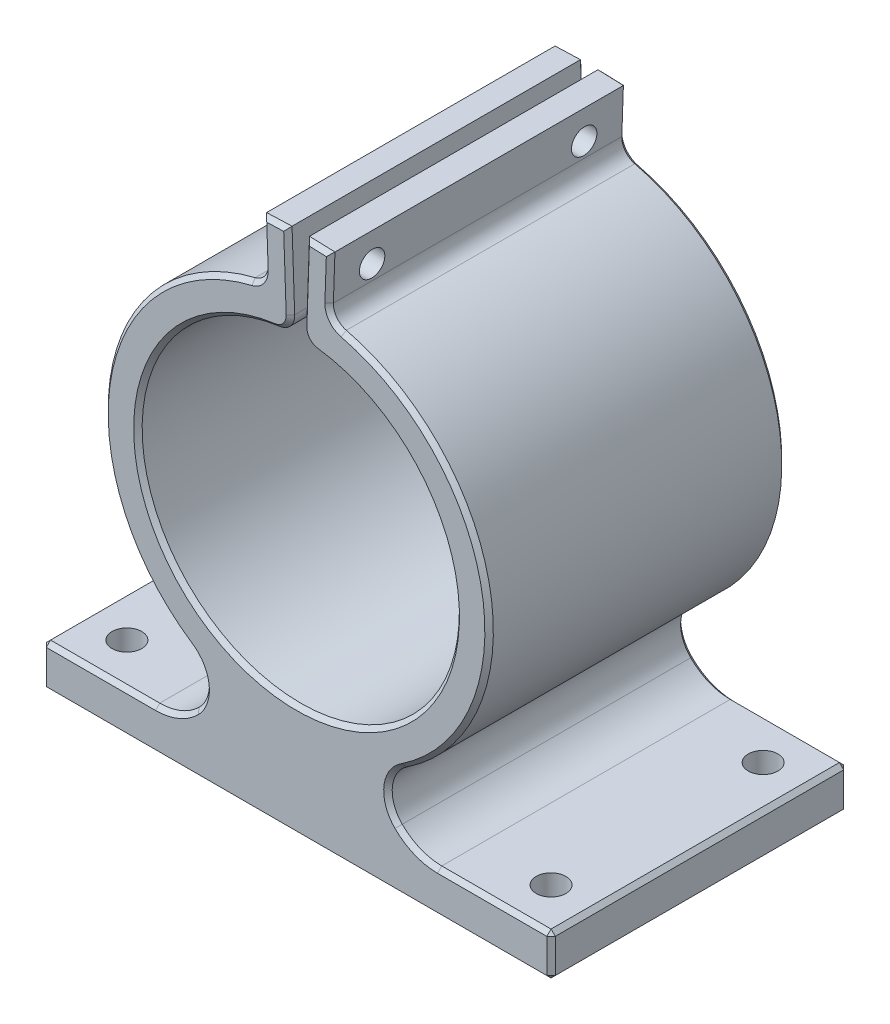
from build123d import *

# Parameters (mm, degrees)
BOSS_EXTRUDE1_DEPTH     = 35
SKETCH2_R               = 1.5
CUT_EXTRUDE1_DEPTH      = 31
CUT_EXTRUDE1_DEPTH_BACK = 31
SKETCH3_R               = 1.75
CUT_EXTRUDE2_DEPTH      = 6
FILLET1_R               = 4
FILLET2_R               = 2
CHAMFER1_SIZE           = 0.5


with BuildPart() as part:
    # Sketch1 → Boss-Extrude1 (new body)
    with BuildSketch(Plane.XY):
        with BuildLine():
            ThreePointArc((-10, -15.801582199), (-18.048902858, 4.891534078), (-0.652620588, 18.688608465))
            Line((-0.652620588, 18.688608465), (-0.792218575, 22.686171773))
            ThreePointArc((-0.792218575, 22.686171773), (-2.292863817, 22.583905232), (-3.783442178, 22.382483448))
            ThreePointArc((-3.783442178, 22.382483448), (-22.463854977, 3.265764775), (-10, -20.378665314))
            Line((-10, -20.378665314), (-10, -15.801582199))
        make_face()
        with BuildLine():
            Line((0, -22.7), (0, -18.7))
            ThreePointArc((0, -18.7), (-5.205785862, -17.960784882), (-10, -15.801582199))
            Line((-10, -15.801582199), (-10, -20.378665314))
            ThreePointArc((-10, -20.378665314), (-5.132947368, -22.112052173), (0, -22.7))
        make_face()
        with BuildLine():
            ThreePointArc((10, -15.801582199), (5.205785862, -17.960784882), (0, -18.7))
            Line((0, -18.7), (0, -22.7))
            ThreePointArc((0, -22.7), (5.132947368, -22.112052173), (10, -20.378665314))
            Line((10, -20.378665314), (10, -15.801582199))
        make_face()
        with BuildLine():
            Line((0.792218575, 22.686171773), (0.652620588, 18.688608465))
            ThreePointArc((0.652620588, 18.688608465), (18.048902858, 4.891534078), (10, -15.801582199))
            Line((10, -15.801582199), (10, -20.378665314))
            ThreePointArc((10, -20.378665314), (22.463854977, 3.265764775), (3.783442178, 22.382483448))
            ThreePointArc((3.783442178, 22.382483448), (2.292863817, 22.583905232), (0.792218575, 22.686171773))
        make_face()
        with BuildLine():
            ThreePointArc((10, -20.378665314), (5.132947368, -22.112052173), (0, -22.7))
            Line((0, -22.7), (0, -32))
            Line((0, -32), (30, -32))
            Line((30, -32), (30, -27))
            Line((30, -27), (16.621334686, -27))
            ThreePointArc((16.621334686, -27), (11.939344029, -25.060655971), (10, -20.378665314))
        make_face()
        with BuildLine():
            Line((0, -32), (0, -22.7))
            ThreePointArc((0, -22.7), (-5.132947368, -22.112052173), (-10, -20.378665314))
            ThreePointArc((-10, -20.378665314), (-11.939344029, -25.060655971), (-16.621334686, -27))
            Line((-16.621334686, -27), (-30, -27))
            Line((-30, -27), (-30, -32))
            Line((-30, -32), (0, -32))
        make_face()
        with BuildLine():
            ThreePointArc((-3.783442178, 22.382483448), (-2.292863817, 22.583905232), (-0.792218575, 22.686171773))
            Line((-0.792218575, 22.686171773), (-1.029566174, 29.482917727))
            Line((-1.029566174, 29.482917727), (-4.027738655, 29.378219237))
            Line((-4.027738655, 29.378219237), (-3.783442178, 22.382483448))
        make_face()
        with BuildLine():
            Line((1.029566174, 29.482917727), (0.792218575, 22.686171773))
            ThreePointArc((0.792218575, 22.686171773), (2.292863817, 22.583905232), (3.783442178, 22.382483448))
            Line((3.783442178, 22.382483448), (4.027738655, 29.378219237))
            Line((4.027738655, 29.378219237), (1.029566174, 29.482917727))
        make_face()
    extrude(amount=BOSS_EXTRUDE1_DEPTH)

    # Sketch2 → Cut-Extrude1 (cut, two sides)
    with BuildSketch(Plane(origin=(0, 0, 0), x_dir=(0, 0, -1), z_dir=(1, 0, 0))) as cut_extrude1_sk:
        with Locations((-30, 25.880351342)):
            Circle(SKETCH2_R)
        with Locations((-5, 25.880351342)):
            Circle(SKETCH2_R)
    extrude(amount=CUT_EXTRUDE1_DEPTH, mode=Mode.SUBTRACT)
    extrude(cut_extrude1_sk.sketch, amount=-CUT_EXTRUDE1_DEPTH_BACK, mode=Mode.SUBTRACT)

    # Sketch3 → Cut-Extrude2 (cut, through all)
    with BuildSketch(Plane(origin=(0, -27, 0), x_dir=(1, 0, 0), z_dir=(0, 1, 0))):
        with Locations((-25, -5)):
            Circle(SKETCH3_R)
        with Locations((-25, -30)):
            Circle(SKETCH3_R)
        with Locations((25, -30)):
            Circle(SKETCH3_R)
        with Locations((25, -5)):
            Circle(SKETCH3_R)
    extrude(amount=-CUT_EXTRUDE2_DEPTH, mode=Mode.SUBTRACT)

    # Fillet1
    fillet1_edges = [part.edges().sort_by_distance(p)[0] for p in [
        (-10, -20.378665314, 17.5),
        (10, -20.378665314, 17.5),
    ]]
    fillet(fillet1_edges, radius=FILLET1_R)

    # Fillet2
    fillet2_edges = [part.edges().sort_by_distance(p)[0] for p in [
        (-3.783442178, 22.382483448, 17.5),
        (-0.652620588, 18.688608465, 17.5),
        (0.652620588, 18.688608465, 17.5),
        (3.783442178, 22.382483448, 17.5),
    ]]
    fillet(fillet2_edges, radius=FILLET2_R)

    # Chamfer1
    chamfer1_edges = [part.edges().sort_by_distance(p)[0] for p in [
        (30, -29.5, 35),
        (-0.874302959, 25.03676097, 0),
        (-0.874302959, 25.03676097, 35),
        (-22.357902089, 3.926094008, 0),
        (-17.579381492, -6.376154512, 0),
        (0.874302959, 25.03676097, 0),
        (1.190855047, 19.229149784, 0),
        (-1.190855047, 19.229149784, 0),
        (-17.579381492, -6.376154512, 35),
        (0.874302959, 25.03676097, 35),
        (-22.357902089, 3.926094008, 35),
        (1.190855047, 19.229149784, 35),
        (-1.190855047, 19.229149784, 35),
        (4.247231716, 22.791302098, 0),
        (4.247231716, 22.791302098, 35),
        (-4.247231716, 22.791302098, 0),
        (-4.247231716, 22.791302098, 35),
        (23.310667343, -27, 35),
        (-30, -29.5, 0),
        (-23.310667343, -27, 0),
        (-14.099306205, -26.500874504, 0),
        (-3.935041139, 26.723709689, 0),
        (-2.528652414, 29.430568482, 0),
        (14.099306205, -26.500874504, 35),
        (2.528652414, 29.430568482, 0),
        (3.935041139, 26.723709689, 0),
        (14.099306205, -26.500874504, 0),
        (23.310667343, -27, 0),
        (30, -29.5, 0),
        (0, -32, 0),
        (3.935041139, 26.723709689, 35),
        (-30, -32, 17.5),
        (-30, -27, 17.5),
        (30, -27, 17.5),
        (30, -32, 17.5),
        (2.528652414, 29.430568482, 35),
        (0, -32, 35),
        (-2.528652414, 29.430568482, 35),
        (-3.935041139, 26.723709689, 35),
        (-14.099306205, -26.500874504, 35),
        (-23.310667343, -27, 35),
        (-30, -29.5, 35),
        (22.357902089, 3.926094008, 0),
        (22.357902089, 3.926094008, 35),
        (-10.793982585, -21.849764719, 0),
        (-10.793982585, -21.849764719, 35),
        (10.793982585, -21.849764719, 0),
        (10.793982585, -21.849764719, 35),
    ]]
    chamfer(chamfer1_edges, length=CHAMFER1_SIZE)


solid = part.part
